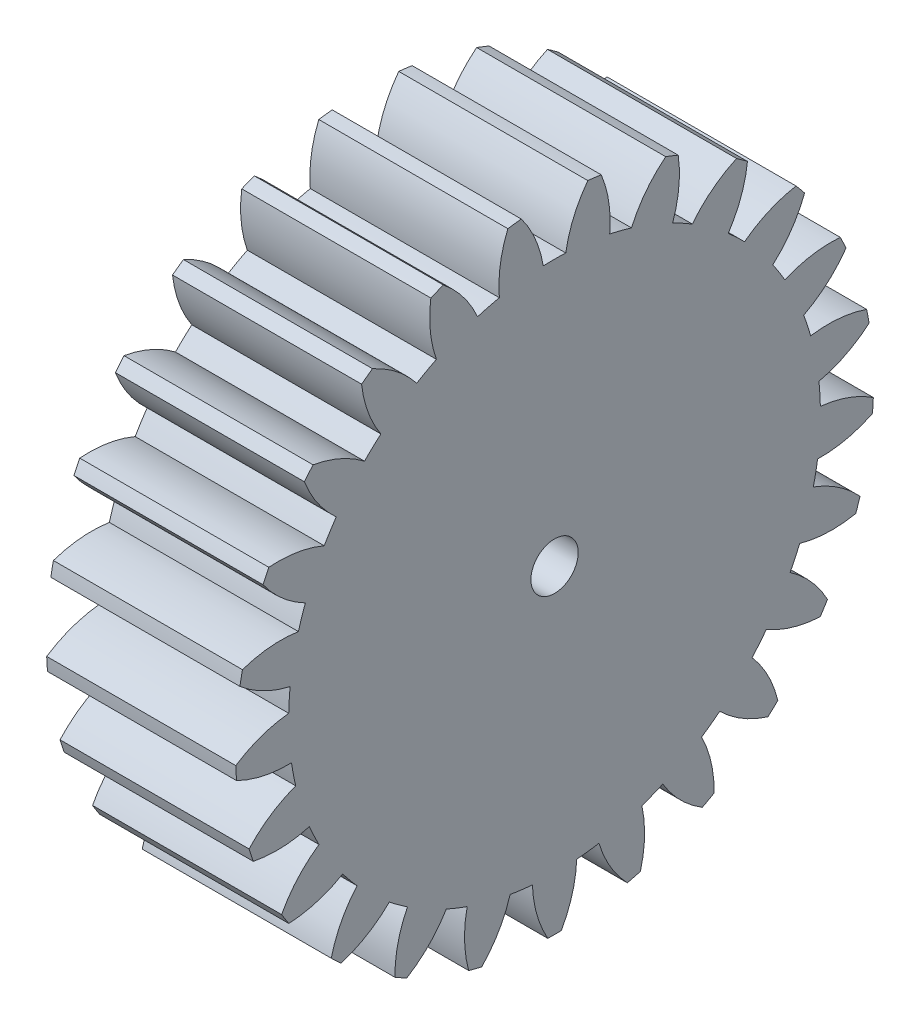
from build123d import *

# Parameters (mm, degrees)
BASPROSKE_W     = 20
BASPROSKE_H     = 33.75
TOOTHCUT_DEPTH  = 52.750603861
TEETHCUTS_COUNT = 25
TEETHCUTS_ANGLE = 345.6
BORSKE_R        = 2.5
BORE_DEPTH      = 50.0000508


with BuildPart() as part:
    # BasProSke → Base-Revolve (revolve)
    with BuildSketch(Plane(origin=(0, 0, 0), x_dir=(1, 0, 0), z_dir=(0, 1, 0)), mode=Mode.PRIVATE) as base_revolve_sk:
        with Locations((10, 16.875)):
            Rectangle(BASPROSKE_W, BASPROSKE_H)
    revolve(base_revolve_sk.sketch.rotate(Axis((-10, 0, 0), (1, 0, 0)), 180), axis=Axis((-10, 0, 0), (1, 0, 0)))

    # TooCutSke → ToothCut (cut, through all)
    with BuildSketch(Plane(origin=(0, 0, 0), x_dir=(0, 0, -1), z_dir=(1, 0, 0))):
        with BuildLine():
            ThreePointArc((1.187856988, 28.098903391), (0, 28.124), (-1.187856988, 28.098903391))
            ThreePointArc((-1.187856988, 28.098903391), (-2.030425927, 30.986675992), (-3.538502421, 33.589531789))
            ThreePointArc((-3.538502421, 33.589531789), (0, 33.7754), (3.538502421, 33.589531789))
            ThreePointArc((3.538502421, 33.589531789), (2.030425927, 30.986675992), (1.187856988, 28.098903391))
        make_face()
    toothcut = extrude(amount=TOOTHCUT_DEPTH, mode=Mode.SUBTRACT)

    # TeethCuts: ToothCut ×25 about axis
    teethcuts_axis = Axis((-10, 0, 0), (1, 0, 0))
    for i in range(1, TEETHCUTS_COUNT):
        add(toothcut.rotate(teethcuts_axis, i * TEETHCUTS_ANGLE / (TEETHCUTS_COUNT - 1)), mode=Mode.SUBTRACT)

    # BorSke → Bore (cut, symmetric)
    with BuildSketch(Plane(origin=(0, 0, 0), x_dir=(0, 0, -1), z_dir=(1, 0, 0))):
        with Locations(Location((0, 0, 0), (0, 0, 180))):
            Circle(BORSKE_R)
    extrude(amount=BORE_DEPTH, both=True, mode=Mode.SUBTRACT)


solid = part.part
